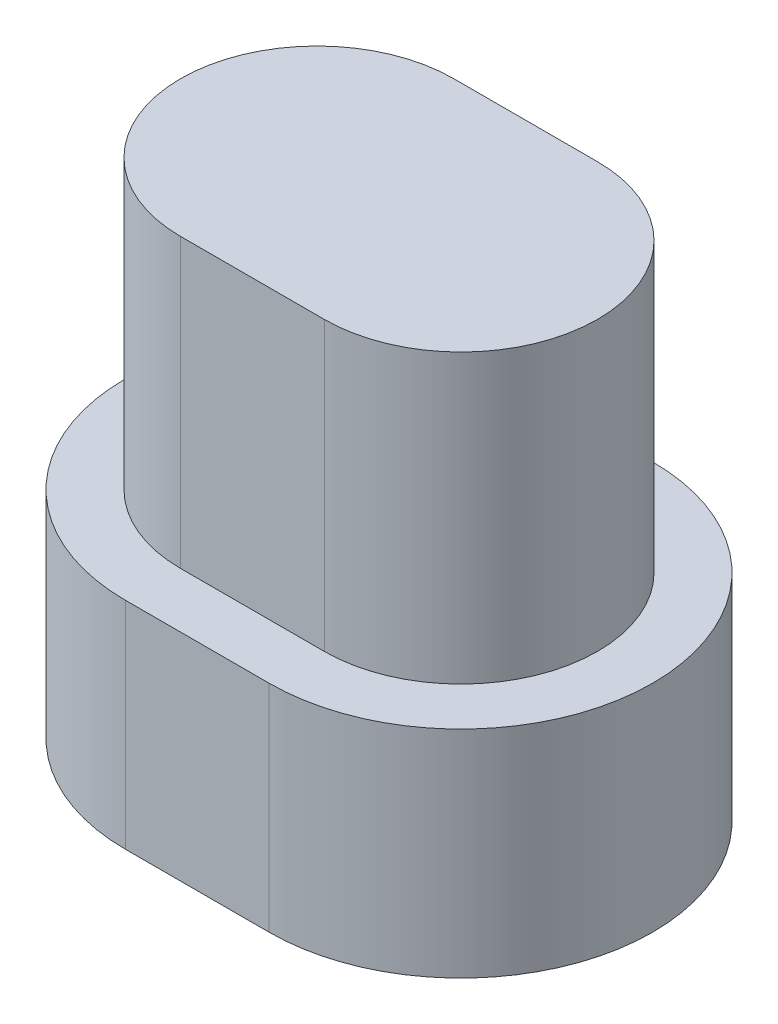
from build123d import *

# Parameters (mm, degrees)
EXTRUDE_1_DEPTH = 6
EXTRUDE_2_DEPTH = 4.5


with BuildPart() as part:
    # 草图1 → 凸台-拉伸1 (new body)
    with BuildSketch(Plane(origin=(0, 0, 0), x_dir=(1, 0, 0), z_dir=(0, 1, 0))):
        with BuildLine():
            Line((0, 2.85), (3, 2.85))
            ThreePointArc((3, 2.85), (5.85, 0), (3, -2.85))
            Line((3, -2.85), (0, -2.85))
            ThreePointArc((0, -2.85), (-2.85, 0), (0, 2.85))
        make_face()
    extrude(amount=EXTRUDE_1_DEPTH)

    # 草图2 → 凸台-拉伸2 (add)
    with BuildSketch(Plane.XZ):
        with BuildLine():
            Line((0, 4), (3, 4))
            ThreePointArc((3, 4), (7, 0), (3, -4))
            Line((3, -4), (0, -4))
            ThreePointArc((0, -4), (-4, 0), (0, 4))
        make_face()
    extrude(amount=EXTRUDE_2_DEPTH)


solid = part.part
